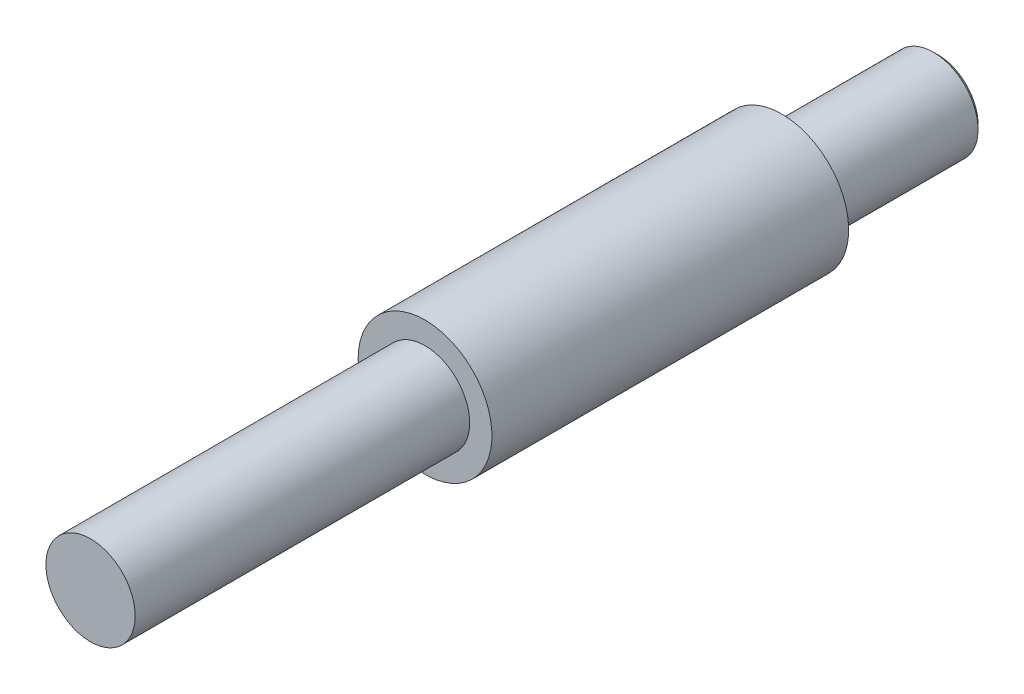
from build123d import *

# Parameters (mm, degrees)
SKETCH1_R           = 10.01
BOSS_EXTRUDE1_DEPTH = 75
SKETCH2_R           = 15
BOSS_EXTRUDE2_DEPTH = 80
SKETCH3_R           = 10.01
BOSS_EXTRUDE3_DEPTH = 35
CHAMFER1_SIZE       = 1


with BuildPart() as part:
    # Sketch1 → Boss-Extrude1 (new body)
    with BuildSketch(Plane.XY):
        Circle(SKETCH1_R)
    extrude(amount=-BOSS_EXTRUDE1_DEPTH)

    # Sketch2 → Boss-Extrude2 (add)
    with BuildSketch(Plane(origin=(0, 0, -75), x_dir=(-1, 0, 0), z_dir=(0, 0, -1))):
        Circle(SKETCH2_R)
    extrude(amount=BOSS_EXTRUDE2_DEPTH)

    # Sketch3 → Boss-Extrude3 (add)
    with BuildSketch(Plane(origin=(0, 0, -155), x_dir=(-1, 0, 0), z_dir=(0, 0, -1))):
        Circle(SKETCH3_R)
    extrude(amount=BOSS_EXTRUDE3_DEPTH)

    # Chamfer1
    chamfer1_edges = [part.edges().sort_by_distance(p)[0] for p in [
        (10.01, 0, -190),
    ]]
    chamfer(chamfer1_edges, length=CHAMFER1_SIZE)


solid = part.part
